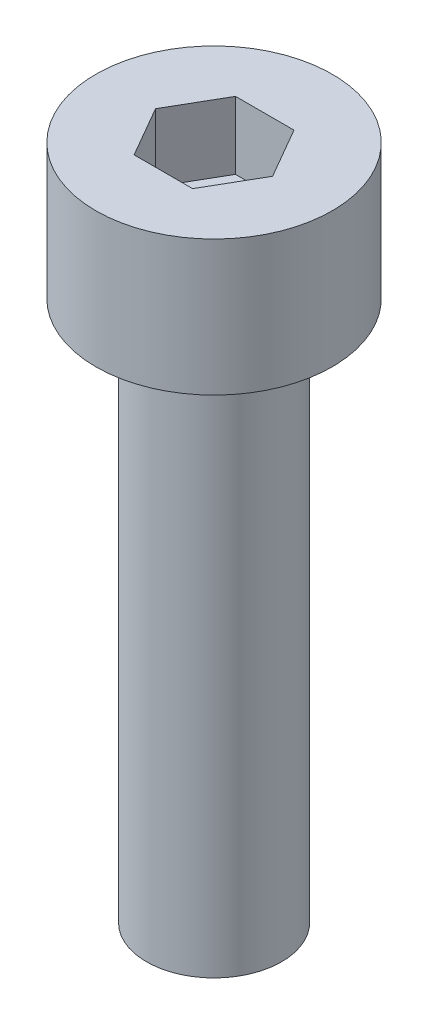
from build123d import *

# Parameters (mm, degrees)
SKETCH_1_R            = 3.5
EXTRUDE_249_DEPTH     = 4
CUT_EXTRUDE_379_DEPTH = 2
SKETCH_3_R            = 2
EXTRUDE_480_DEPTH     = 16


with BuildPart() as part:
    # 草图1 → Extrude 249 (new body)
    with BuildSketch(Plane(origin=(0, 0, 0), x_dir=(1, 0, 0), z_dir=(0, 1, 0))):
        Circle(SKETCH_1_R)
    extrude(amount=EXTRUDE_249_DEPTH)

    # 草图2 → Cut-Extrude 379 (cut)
    with BuildSketch(Plane(origin=(0, 4, 0), x_dir=(1, 0, 0), z_dir=(0, 1, 0))):
        Polygon((1.732050808, 0), (0.866025404, 1.5), (-0.866025404, 1.5), (-1.732050808, 0), (-0.866025404, -1.5), (0.866025404, -1.5), align=None)
    extrude(amount=-CUT_EXTRUDE_379_DEPTH, mode=Mode.SUBTRACT)

    # 草图3 → Extrude 480 (add)
    with BuildSketch(Plane.XZ):
        Circle(SKETCH_3_R)
    extrude(amount=EXTRUDE_480_DEPTH)


solid = part.part
